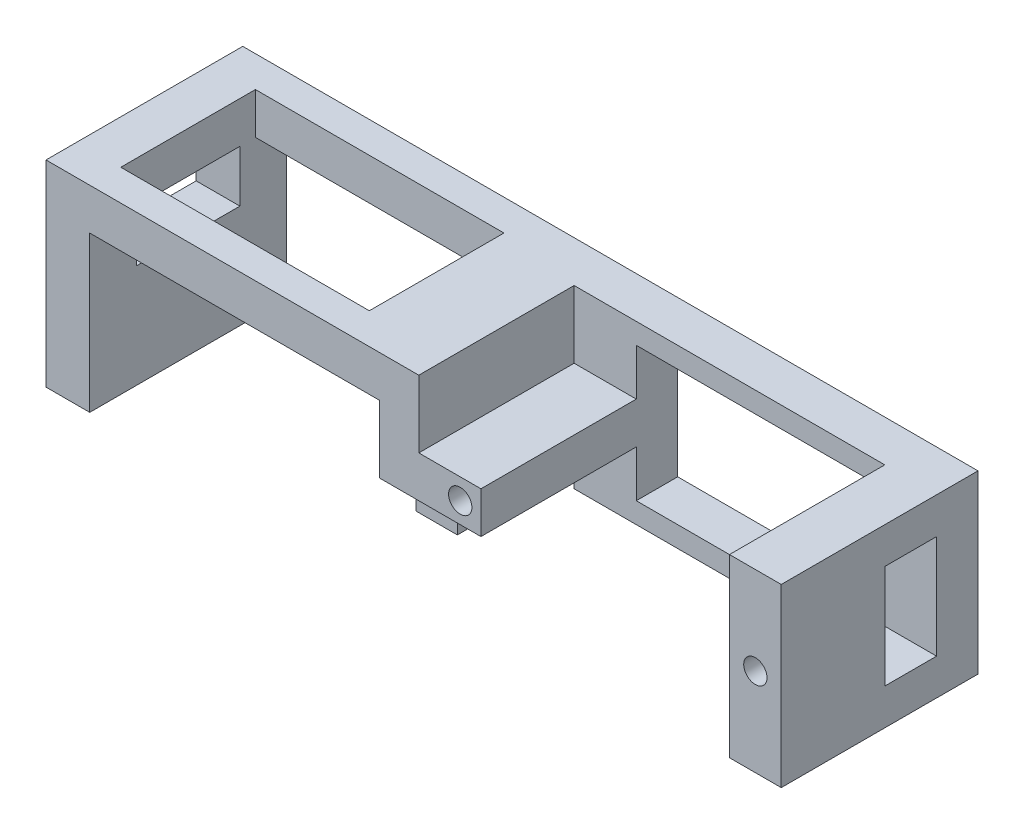
from build123d import *

# Parameters (mm, degrees)
SKETCH_1_W           = 35
SKETCH_1_H           = 17
EXTRUDE_1_DEPTH      = 4
SKETCH_2_W           = 24
SKETCH_2_H           = 13
CUT_EXTRUDE_1_DEPTH  = 6
EXTRUDE_2_DEPTH      = 5
SKETCH_5_W           = 4
SKETCH_5_H           = 4
SKETCH_5_R           = 1.125
EXTRUDE_3_DEPTH      = 15
SKETCH_6_R           = 1.125
CUT_EXTRUDE_2_DEPTH  = 15
EXTRUDE_5_DEPTH      = 2
SKETCH_8_W           = 36
SKETCH_8_H           = 19
EXTRUDE_6_DEPTH      = 8.3
EXTRUDE_6_DEPTH_BACK = 10.7
SKETCH_9_W           = 24
SKETCH_9_H           = 13
CUT_EXTRUDE_3_DEPTH  = 22
SKETCH_11_R          = 1.125
CUT_EXTRUDE_4_DEPTH  = 15
CUT_EXTRUDE_5_DEPTH  = 15
SKETCH_13_W          = 3.77735738
SKETCH_13_H          = 19
CUT_EXTRUDE_6_DEPTH  = 8.5
SKETCH_14_W          = 10
SKETCH_14_H          = 5
CUT_EXTRUDE_7_DEPTH  = 10


with BuildPart() as part:
    # 草圖1 → 填料-伸長1 (new body)
    with BuildSketch(Plane.XY):
        with Locations((-3.721052632, 2.8)):
            Rectangle(SKETCH_1_W, SKETCH_1_H)
    extrude(amount=EXTRUDE_1_DEPTH)

    # 草圖2 → 除料-伸長1 (cut)
    with BuildSketch(Plane.XY):
        with Locations((-3.221052632, 2.8)):
            Rectangle(SKETCH_2_W, SKETCH_2_H)
    extrude(amount=CUT_EXTRUDE_1_DEPTH, mode=Mode.SUBTRACT)

    # 草圖3 → 填料-伸長2 (add)
    with BuildSketch(Plane(origin=(13.778947368, 0, 0), x_dir=(0, 0, -1), z_dir=(1, 0, 0))):
        Polygon((-4, 7.802538439), (-4, 11.3), (-19, 11.3), (-19, -5.694923122), (-4, -5.694923122), (-4, -2.197461561), (-9, -2.197461561), (-9, 7.802538439), align=None)
    extrude(amount=-EXTRUDE_2_DEPTH)

    # 草圖5 → 填料-伸長3 (add)
    with BuildSketch(Plane.XY.offset(4)):
        with Locations((-17.221052632, 2.8)):
            Rectangle(SKETCH_5_W, SKETCH_5_H)
        with Locations((-17.221052632, 2.8)):
            Circle(SKETCH_5_R, mode=Mode.SUBTRACT)
    extrude(amount=EXTRUDE_3_DEPTH)

    # 草圖6 → 除料-伸長2 (cut)
    with BuildSketch(Plane.XY.offset(19)):
        with Locations((11.278947368, 2.802538439)):
            Circle(SKETCH_6_R)
    extrude(amount=-CUT_EXTRUDE_2_DEPTH, mode=Mode.SUBTRACT)

    # 草圖7 → 填料-伸長5 (add)
    with BuildSketch(Plane.ZY.offset(21.221052632)):
        Polygon((4, 4.8), (4, 0.796544916), (19, 0.8), (19, 4.8), align=None)
    extrude(amount=-EXTRUDE_5_DEPTH)

    # 草圖8 → 填料-伸長6 (add, two sides)
    with BuildSketch(Plane(origin=(0, 3, 0), x_dir=(1, 0, 0), z_dir=(0, 1, 0))) as extrude_6_sk:
        with Locations((-39.221052632, -9.5)):
            Rectangle(SKETCH_8_W, SKETCH_8_H)
    extrude(amount=EXTRUDE_6_DEPTH)
    extrude(extrude_6_sk.sketch, amount=-EXTRUDE_6_DEPTH_BACK)

    # 草圖9 → 除料-伸長3 (cut)
    with BuildSketch(Plane(origin=(0, 11.3, 0), x_dir=(1, 0, 0), z_dir=(0, 1, 0))):
        with Locations((-40.998410012, -9.5)):
            Rectangle(SKETCH_9_W, SKETCH_9_H)
    extrude(amount=-CUT_EXTRUDE_3_DEPTH, mode=Mode.SUBTRACT)

    # 草圖11 → 除料-伸長4 (cut)
    with BuildSketch(Plane(origin=(0, -7.7, 0), x_dir=(-1, 0, 0), z_dir=(0, -1, 0))):
        with Locations((26.998410012, -9.5)):
            Circle(SKETCH_11_R)
        with Locations((54.999503046, -9.5)):
            Circle(SKETCH_11_R)
    extrude(amount=-CUT_EXTRUDE_4_DEPTH, mode=Mode.SUBTRACT)

    # 草圖12 → 除料-伸長5 (cut)
    with BuildSketch(Plane(origin=(0, -7.7, 0), x_dir=(-1, 0, 0), z_dir=(0, -1, 0))):
        Polygon((28.998410012, -7.5), (24.998410012, -7.5), (24.998410012, 0), (52.998410012, 0), (52.998410012, -3), (28.998410012, -3), align=None)
        Polygon((24.998410012, -11.5), (24.998410012, -19), (52.998410012, -19), (52.998410012, -16), (28.998410012, -16), (28.998410012, -11.5), align=None)
    extrude(amount=-CUT_EXTRUDE_5_DEPTH, mode=Mode.SUBTRACT)

    # 草圖13 → 除料-伸長6 (cut)
    with BuildSketch(Plane.XZ.offset(7.7)):
        with Locations((-23.109731322, 9.5)):
            Rectangle(SKETCH_13_W, SKETCH_13_H)
    extrude(amount=-CUT_EXTRUDE_6_DEPTH, mode=Mode.SUBTRACT)

    # 草圖14 → 除料-伸長7 (cut)
    with BuildSketch(Plane.ZY.offset(57.221052632)):
        with Locations((9.5, 4.8)):
            Rectangle(SKETCH_14_W, SKETCH_14_H)
    extrude(amount=-CUT_EXTRUDE_7_DEPTH, mode=Mode.SUBTRACT)


solid = part.part
